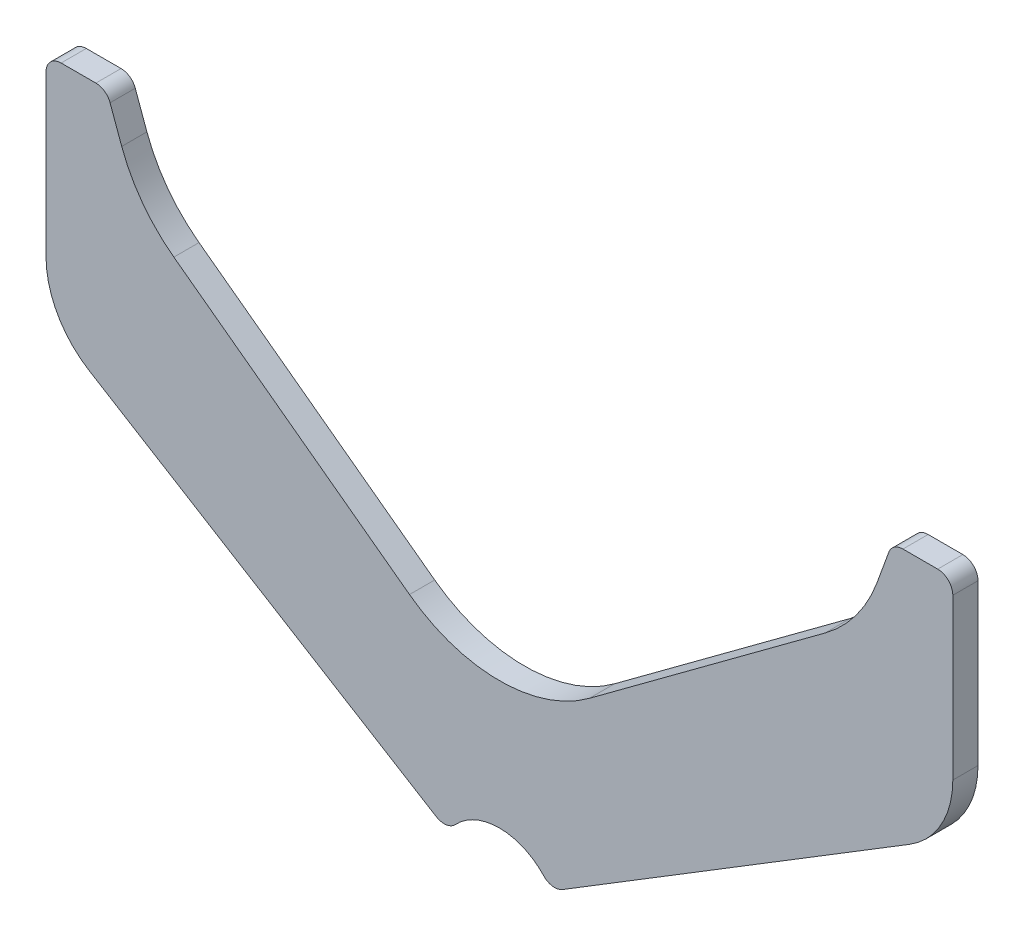
from build123d import *

# Parameters (mm, degrees)
BASE_EXTRUDE_DEPTH = 5


with BuildPart() as part:
    # Sketch1 → Base-Extrude (new body)
    with BuildSketch(Plane.XY):
        with BuildLine():
            Line((-90, 97), (-90, 65.232555285))
            ThreePointArc((-90, 65.232555285), (-87.704928127, 56.437372938), (-81.404974165, 49.885032327))
            Line((-81.404974165, 49.885032327), (-12.531200021, 7.679129249))
            ThreePointArc((-12.531200021, 7.679129249), (-10.560110304, 7.264321725), (-8.770963462, 8.189639794))
            ThreePointArc((-8.770963462, 8.189639794), (0, 12), (8.770963462, 8.189639794))
            ThreePointArc((8.770963462, 8.189639794), (10.560110304, 7.264321725), (12.531200021, 7.679129249))
            Line((12.531200021, 7.679129249), (81.404974165, 49.885032327))
            ThreePointArc((81.404974165, 49.885032327), (87.704928127, 56.437372938), (90, 65.232555285))
            Line((90, 65.232555285), (90, 97))
            ThreePointArc((90, 97), (89.121320344, 99.121320344), (87, 100))
            Line((87, 100), (80.100622615, 100))
            ThreePointArc((80.100622615, 100), (78.379893306, 99.457456133), (77.281544752, 98.02606043))
            Line((77.281544752, 98.02606043), (74.969567775, 91.67395589))
            ThreePointArc((74.969567775, 91.67395589), (70.816403532, 83.984822172), (64.623472754, 77.818854371))
            Line((64.623472754, 77.818854371), (17.844683603, 43.204371262))
            ThreePointArc((17.844683603, 43.204371262), (0, 37.320077081), (-17.844683603, 43.204371262))
            Line((-17.844683603, 43.204371262), (-64.623472754, 77.818854371))
            ThreePointArc((-64.623472754, 77.818854371), (-70.816403532, 83.984822172), (-74.969567775, 91.67395589))
            Line((-74.969567775, 91.67395589), (-77.281544752, 98.02606043))
            ThreePointArc((-77.281544752, 98.02606043), (-78.379893306, 99.457456133), (-80.100622615, 100))
            Line((-80.100622615, 100), (-87, 100))
            ThreePointArc((-87, 100), (-89.121320344, 99.121320344), (-90, 97))
        make_face()
    extrude(amount=BASE_EXTRUDE_DEPTH)


solid = part.part
